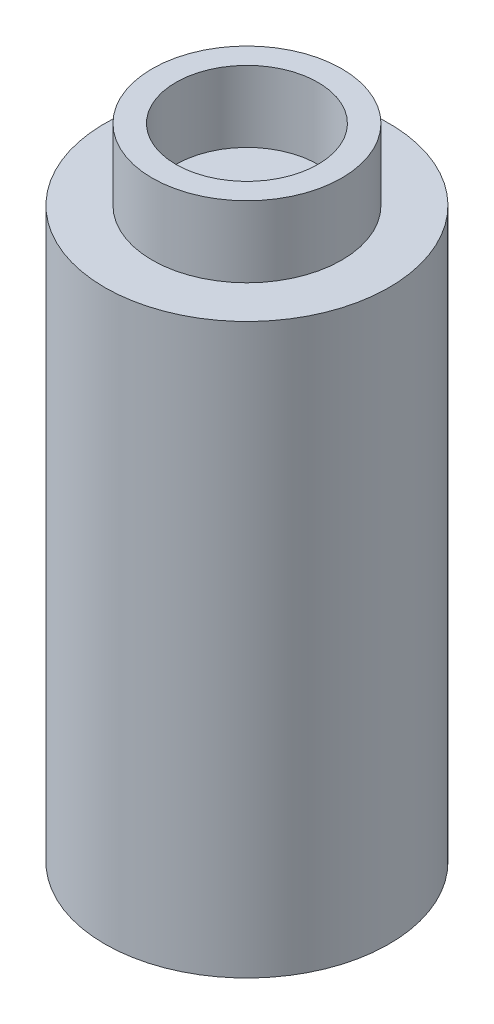
from build123d import *

# Parameters (mm, degrees)
SKETCH2_R           = 6
BOSS_EXTRUDE1_DEPTH = 24
SKETCH3_R           = 4
BOSS_EXTRUDE2_DEPTH = 3
SKETCH4_R           = 3
CUT_EXTRUDE1_DEPTH  = 3


with BuildPart() as part:
    # Sketch2 → Boss-Extrude1 (new body)
    with BuildSketch(Plane(origin=(0, 0, 0), x_dir=(1, 0, 0), z_dir=(0, 1, 0))):
        Circle(SKETCH2_R)
    extrude(amount=BOSS_EXTRUDE1_DEPTH)

    # Sketch3 → Boss-Extrude2 (add)
    with BuildSketch(Plane(origin=(0, 24, 0), x_dir=(1, 0, 0), z_dir=(0, 1, 0))):
        Circle(SKETCH3_R)
    extrude(amount=BOSS_EXTRUDE2_DEPTH)

    # Sketch4 → Cut-Extrude1 (cut)
    with BuildSketch(Plane(origin=(0, 27, 0), x_dir=(1, 0, 0), z_dir=(0, 1, 0))):
        Circle(SKETCH4_R)
    extrude(amount=-CUT_EXTRUDE1_DEPTH, mode=Mode.SUBTRACT)


solid = part.part
